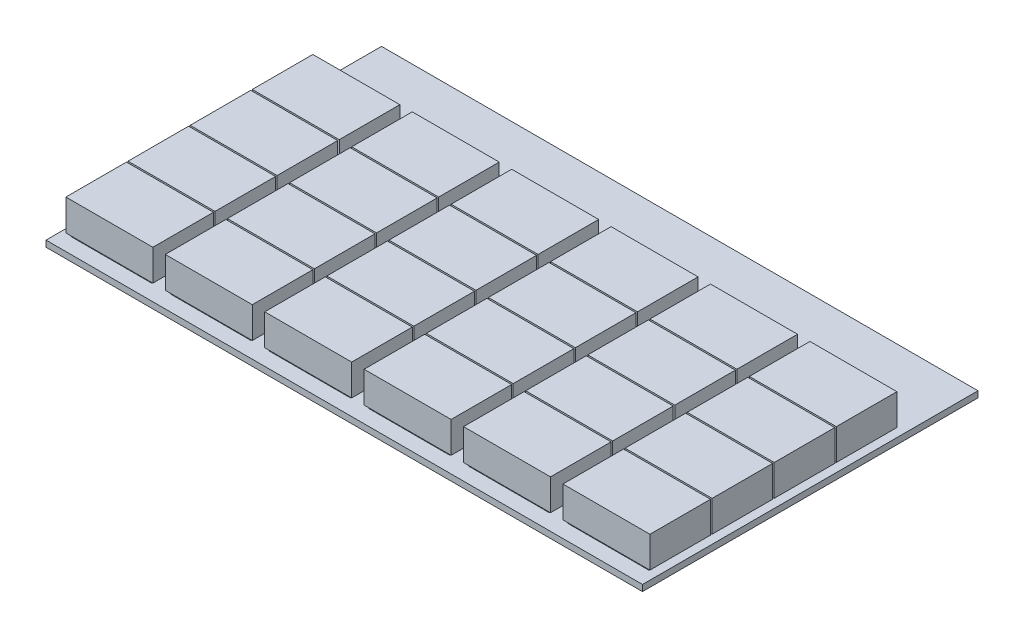
from build123d import *

# Parameters (mm, degrees)
SKETCH1_W                  = 80
SKETCH1_H                  = 270
BOSS_EXTRUDE1_DEPTH        = 5
SKETCH2_W                  = 65
SKETCH2_H                  = 45
BOSS_EXTRUDE3_DEPTH        = 2
LPATTERN1_COUNT            = 4
LPATTERN1_PITCH            = 50
SKETCH3_W                  = 70
SKETCH3_H                  = 48.748964222
BOSS_EXTRUDE8_DEPTH        = 25
LPATTERN5_COUNT            = 4
LPATTERN5_PITCH            = 50
LPATTERN6_COUNT            = 6
LPATTERN6_PITCH            = 80
LPATTERN6_COPY_1_SKETCH_W  = 65
LPATTERN6_COPY_1_SKETCH_H  = 45
LPATTERN6_COPY_1_DEPTH     = 2
LPATTERN6_COPY_2_SKETCH_W  = 65
LPATTERN6_COPY_2_SKETCH_H  = 45
LPATTERN6_COPY_2_DEPTH     = 2
LPATTERN6_COPY_3_SKETCH_W  = 65
LPATTERN6_COPY_3_SKETCH_H  = 45
LPATTERN6_COPY_3_DEPTH     = 2
LPATTERN6_COPY_4_SKETCH_W  = 65
LPATTERN6_COPY_4_SKETCH_H  = 45
LPATTERN6_COPY_4_DEPTH     = 2
LPATTERN6_COPY_5_SKETCH_W  = 65
LPATTERN6_COPY_5_SKETCH_H  = 45
LPATTERN6_COPY_5_DEPTH     = 2
LPATTERN6_COPY_6_SKETCH_W  = 65
LPATTERN6_COPY_6_SKETCH_H  = 45
LPATTERN6_COPY_6_DEPTH     = 2
LPATTERN6_COPY_7_SKETCH_W  = 65
LPATTERN6_COPY_7_SKETCH_H  = 45
LPATTERN6_COPY_7_DEPTH     = 2
LPATTERN6_COPY_8_SKETCH_W  = 65
LPATTERN6_COPY_8_SKETCH_H  = 45
LPATTERN6_COPY_8_DEPTH     = 2
LPATTERN6_COPY_9_SKETCH_W  = 65
LPATTERN6_COPY_9_SKETCH_H  = 45
LPATTERN6_COPY_9_DEPTH     = 2
LPATTERN6_COPY_10_SKETCH_W = 65
LPATTERN6_COPY_10_SKETCH_H = 45
LPATTERN6_COPY_10_DEPTH    = 2
LPATTERN6_COPY_11_SKETCH_W = 65
LPATTERN6_COPY_11_SKETCH_H = 45
LPATTERN6_COPY_11_DEPTH    = 2
LPATTERN6_COPY_12_SKETCH_W = 65
LPATTERN6_COPY_12_SKETCH_H = 45
LPATTERN6_COPY_12_DEPTH    = 2
LPATTERN6_COPY_13_SKETCH_W = 65
LPATTERN6_COPY_13_SKETCH_H = 45
LPATTERN6_COPY_13_DEPTH    = 2
LPATTERN6_COPY_14_SKETCH_W = 65
LPATTERN6_COPY_14_SKETCH_H = 45
LPATTERN6_COPY_14_DEPTH    = 2
LPATTERN6_COPY_15_SKETCH_W = 65
LPATTERN6_COPY_15_SKETCH_H = 45
LPATTERN6_COPY_15_DEPTH    = 2
LPATTERN6_COPY_16_SKETCH_W = 70
LPATTERN6_COPY_16_SKETCH_H = 48.748964222
LPATTERN6_COPY_16_DEPTH    = 25
LPATTERN6_COPY_17_SKETCH_W = 70
LPATTERN6_COPY_17_SKETCH_H = 48.748964222
LPATTERN6_COPY_17_DEPTH    = 25
LPATTERN6_COPY_18_SKETCH_W = 70
LPATTERN6_COPY_18_SKETCH_H = 48.748964222
LPATTERN6_COPY_18_DEPTH    = 25
LPATTERN6_COPY_19_SKETCH_W = 70
LPATTERN6_COPY_19_SKETCH_H = 48.748964222
LPATTERN6_COPY_19_DEPTH    = 25
LPATTERN6_COPY_20_SKETCH_W = 70
LPATTERN6_COPY_20_SKETCH_H = 48.748964222
LPATTERN6_COPY_20_DEPTH    = 25
LPATTERN6_COPY_21_SKETCH_W = 70
LPATTERN6_COPY_21_SKETCH_H = 48.748964222
LPATTERN6_COPY_21_DEPTH    = 25
LPATTERN6_COPY_22_SKETCH_W = 70
LPATTERN6_COPY_22_SKETCH_H = 48.748964222
LPATTERN6_COPY_22_DEPTH    = 25
LPATTERN6_COPY_23_SKETCH_W = 70
LPATTERN6_COPY_23_SKETCH_H = 48.748964222
LPATTERN6_COPY_23_DEPTH    = 25
LPATTERN6_COPY_24_SKETCH_W = 70
LPATTERN6_COPY_24_SKETCH_H = 48.748964222
LPATTERN6_COPY_24_DEPTH    = 25
LPATTERN6_COPY_25_SKETCH_W = 70
LPATTERN6_COPY_25_SKETCH_H = 48.748964222
LPATTERN6_COPY_25_DEPTH    = 25
LPATTERN6_COPY_26_SKETCH_W = 70
LPATTERN6_COPY_26_SKETCH_H = 48.748964222
LPATTERN6_COPY_26_DEPTH    = 25
LPATTERN6_COPY_27_SKETCH_W = 70
LPATTERN6_COPY_27_SKETCH_H = 48.748964222
LPATTERN6_COPY_27_DEPTH    = 25
LPATTERN6_COPY_28_SKETCH_W = 70
LPATTERN6_COPY_28_SKETCH_H = 48.748964222
LPATTERN6_COPY_28_DEPTH    = 25
LPATTERN6_COPY_29_SKETCH_W = 70
LPATTERN6_COPY_29_SKETCH_H = 48.748964222
LPATTERN6_COPY_29_DEPTH    = 25
LPATTERN6_COPY_30_SKETCH_W = 70
LPATTERN6_COPY_30_SKETCH_H = 48.748964222
LPATTERN6_COPY_30_DEPTH    = 25


with BuildPart() as part:
    # Sketch1 → Boss-Extrude1 (new body)
    with BuildSketch(Plane(origin=(0, 0, 0), x_dir=(1, 0, 0), z_dir=(0, 1, 0))):
        Rectangle(SKETCH1_W, SKETCH1_H)
    boss_extrude1 = extrude(amount=BOSS_EXTRUDE1_DEPTH)

    # Sketch2 → Boss-Extrude3 (add)
    with BuildSketch(Plane(origin=(0, 5, 0), x_dir=(1, 0, 0), z_dir=(0, 1, 0))):
        with Locations((0, -100)):
            Rectangle(SKETCH2_W, SKETCH2_H)
    boss_extrude3 = extrude(amount=BOSS_EXTRUDE3_DEPTH)

    # LPattern1: Boss-Extrude3 ×4
    with Locations(*[(0, 0, -i * LPATTERN1_PITCH) for i in range(1, LPATTERN1_COUNT)]):
        add(boss_extrude3)

    # Sketch3 → Boss-Extrude8 (add)
    with BuildSketch(Plane(origin=(0, 7, 0), x_dir=(1, 0, 0), z_dir=(0, 1, 0))):
        with Locations((0, -99.635002086)):
            Rectangle(SKETCH3_W, SKETCH3_H)
    boss_extrude8 = extrude(amount=BOSS_EXTRUDE8_DEPTH)

    # LPattern5: Boss-Extrude8 ×4
    with Locations(*[(0, 0, -i * LPATTERN5_PITCH) for i in range(1, LPATTERN5_COUNT)]):
        add(boss_extrude8)

    # LPattern6: Boss-Extrude1, Boss-Extrude3, Boss-Extrude8 ×6
    with Locations(*[(-i * LPATTERN6_PITCH, 0, 0) for i in range(1, LPATTERN6_COUNT)]):
        add(boss_extrude1)
        add(boss_extrude3)
        add(boss_extrude8)

    # LPattern6 copy 1 sketch → LPattern6 copy 1 (add)
    with BuildSketch(Plane(origin=(-80, 5, -50), x_dir=(1, 0, 0), z_dir=(0, 1, 0))):
        with Locations((0, -100)):
            Rectangle(LPATTERN6_COPY_1_SKETCH_W, LPATTERN6_COPY_1_SKETCH_H)
    extrude(amount=LPATTERN6_COPY_1_DEPTH)

    # LPattern6 copy 2 sketch → LPattern6 copy 2 (add)
    with BuildSketch(Plane(origin=(-160, 5, -50), x_dir=(1, 0, 0), z_dir=(0, 1, 0))):
        with Locations((0, -100)):
            Rectangle(LPATTERN6_COPY_2_SKETCH_W, LPATTERN6_COPY_2_SKETCH_H)
    extrude(amount=LPATTERN6_COPY_2_DEPTH)

    # LPattern6 copy 3 sketch → LPattern6 copy 3 (add)
    with BuildSketch(Plane(origin=(-240, 5, -50), x_dir=(1, 0, 0), z_dir=(0, 1, 0))):
        with Locations((0, -100)):
            Rectangle(LPATTERN6_COPY_3_SKETCH_W, LPATTERN6_COPY_3_SKETCH_H)
    extrude(amount=LPATTERN6_COPY_3_DEPTH)

    # LPattern6 copy 4 sketch → LPattern6 copy 4 (add)
    with BuildSketch(Plane(origin=(-320, 5, -50), x_dir=(1, 0, 0), z_dir=(0, 1, 0))):
        with Locations((0, -100)):
            Rectangle(LPATTERN6_COPY_4_SKETCH_W, LPATTERN6_COPY_4_SKETCH_H)
    extrude(amount=LPATTERN6_COPY_4_DEPTH)

    # LPattern6 copy 5 sketch → LPattern6 copy 5 (add)
    with BuildSketch(Plane(origin=(-400, 5, -50), x_dir=(1, 0, 0), z_dir=(0, 1, 0))):
        with Locations((0, -100)):
            Rectangle(LPATTERN6_COPY_5_SKETCH_W, LPATTERN6_COPY_5_SKETCH_H)
    extrude(amount=LPATTERN6_COPY_5_DEPTH)

    # LPattern6 copy 6 sketch → LPattern6 copy 6 (add)
    with BuildSketch(Plane(origin=(-80, 5, -100), x_dir=(1, 0, 0), z_dir=(0, 1, 0))):
        with Locations((0, -100)):
            Rectangle(LPATTERN6_COPY_6_SKETCH_W, LPATTERN6_COPY_6_SKETCH_H)
    extrude(amount=LPATTERN6_COPY_6_DEPTH)

    # LPattern6 copy 7 sketch → LPattern6 copy 7 (add)
    with BuildSketch(Plane(origin=(-160, 5, -100), x_dir=(1, 0, 0), z_dir=(0, 1, 0))):
        with Locations((0, -100)):
            Rectangle(LPATTERN6_COPY_7_SKETCH_W, LPATTERN6_COPY_7_SKETCH_H)
    extrude(amount=LPATTERN6_COPY_7_DEPTH)

    # LPattern6 copy 8 sketch → LPattern6 copy 8 (add)
    with BuildSketch(Plane(origin=(-240, 5, -100), x_dir=(1, 0, 0), z_dir=(0, 1, 0))):
        with Locations((0, -100)):
            Rectangle(LPATTERN6_COPY_8_SKETCH_W, LPATTERN6_COPY_8_SKETCH_H)
    extrude(amount=LPATTERN6_COPY_8_DEPTH)

    # LPattern6 copy 9 sketch → LPattern6 copy 9 (add)
    with BuildSketch(Plane(origin=(-320, 5, -100), x_dir=(1, 0, 0), z_dir=(0, 1, 0))):
        with Locations((0, -100)):
            Rectangle(LPATTERN6_COPY_9_SKETCH_W, LPATTERN6_COPY_9_SKETCH_H)
    extrude(amount=LPATTERN6_COPY_9_DEPTH)

    # LPattern6 copy 10 sketch → LPattern6 copy 10 (add)
    with BuildSketch(Plane(origin=(-400, 5, -100), x_dir=(1, 0, 0), z_dir=(0, 1, 0))):
        with Locations((0, -100)):
            Rectangle(LPATTERN6_COPY_10_SKETCH_W, LPATTERN6_COPY_10_SKETCH_H)
    extrude(amount=LPATTERN6_COPY_10_DEPTH)

    # LPattern6 copy 11 sketch → LPattern6 copy 11 (add)
    with BuildSketch(Plane(origin=(-80, 5, -150), x_dir=(1, 0, 0), z_dir=(0, 1, 0))):
        with Locations((0, -100)):
            Rectangle(LPATTERN6_COPY_11_SKETCH_W, LPATTERN6_COPY_11_SKETCH_H)
    extrude(amount=LPATTERN6_COPY_11_DEPTH)

    # LPattern6 copy 12 sketch → LPattern6 copy 12 (add)
    with BuildSketch(Plane(origin=(-160, 5, -150), x_dir=(1, 0, 0), z_dir=(0, 1, 0))):
        with Locations((0, -100)):
            Rectangle(LPATTERN6_COPY_12_SKETCH_W, LPATTERN6_COPY_12_SKETCH_H)
    extrude(amount=LPATTERN6_COPY_12_DEPTH)

    # LPattern6 copy 13 sketch → LPattern6 copy 13 (add)
    with BuildSketch(Plane(origin=(-240, 5, -150), x_dir=(1, 0, 0), z_dir=(0, 1, 0))):
        with Locations((0, -100)):
            Rectangle(LPATTERN6_COPY_13_SKETCH_W, LPATTERN6_COPY_13_SKETCH_H)
    extrude(amount=LPATTERN6_COPY_13_DEPTH)

    # LPattern6 copy 14 sketch → LPattern6 copy 14 (add)
    with BuildSketch(Plane(origin=(-320, 5, -150), x_dir=(1, 0, 0), z_dir=(0, 1, 0))):
        with Locations((0, -100)):
            Rectangle(LPATTERN6_COPY_14_SKETCH_W, LPATTERN6_COPY_14_SKETCH_H)
    extrude(amount=LPATTERN6_COPY_14_DEPTH)

    # LPattern6 copy 15 sketch → LPattern6 copy 15 (add)
    with BuildSketch(Plane(origin=(-400, 5, -150), x_dir=(1, 0, 0), z_dir=(0, 1, 0))):
        with Locations((0, -100)):
            Rectangle(LPATTERN6_COPY_15_SKETCH_W, LPATTERN6_COPY_15_SKETCH_H)
    extrude(amount=LPATTERN6_COPY_15_DEPTH)

    # LPattern6 copy 16 sketch → LPattern6 copy 16 (add)
    with BuildSketch(Plane(origin=(-80, 7, -50), x_dir=(1, 0, 0), z_dir=(0, 1, 0))):
        with Locations((0, -99.635002086)):
            Rectangle(LPATTERN6_COPY_16_SKETCH_W, LPATTERN6_COPY_16_SKETCH_H)
    extrude(amount=LPATTERN6_COPY_16_DEPTH)

    # LPattern6 copy 17 sketch → LPattern6 copy 17 (add)
    with BuildSketch(Plane(origin=(-160, 7, -50), x_dir=(1, 0, 0), z_dir=(0, 1, 0))):
        with Locations((0, -99.635002086)):
            Rectangle(LPATTERN6_COPY_17_SKETCH_W, LPATTERN6_COPY_17_SKETCH_H)
    extrude(amount=LPATTERN6_COPY_17_DEPTH)

    # LPattern6 copy 18 sketch → LPattern6 copy 18 (add)
    with BuildSketch(Plane(origin=(-240, 7, -50), x_dir=(1, 0, 0), z_dir=(0, 1, 0))):
        with Locations((0, -99.635002086)):
            Rectangle(LPATTERN6_COPY_18_SKETCH_W, LPATTERN6_COPY_18_SKETCH_H)
    extrude(amount=LPATTERN6_COPY_18_DEPTH)

    # LPattern6 copy 19 sketch → LPattern6 copy 19 (add)
    with BuildSketch(Plane(origin=(-320, 7, -50), x_dir=(1, 0, 0), z_dir=(0, 1, 0))):
        with Locations((0, -99.635002086)):
            Rectangle(LPATTERN6_COPY_19_SKETCH_W, LPATTERN6_COPY_19_SKETCH_H)
    extrude(amount=LPATTERN6_COPY_19_DEPTH)

    # LPattern6 copy 20 sketch → LPattern6 copy 20 (add)
    with BuildSketch(Plane(origin=(-400, 7, -50), x_dir=(1, 0, 0), z_dir=(0, 1, 0))):
        with Locations((0, -99.635002086)):
            Rectangle(LPATTERN6_COPY_20_SKETCH_W, LPATTERN6_COPY_20_SKETCH_H)
    extrude(amount=LPATTERN6_COPY_20_DEPTH)

    # LPattern6 copy 21 sketch → LPattern6 copy 21 (add)
    with BuildSketch(Plane(origin=(-80, 7, -100), x_dir=(1, 0, 0), z_dir=(0, 1, 0))):
        with Locations((0, -99.635002086)):
            Rectangle(LPATTERN6_COPY_21_SKETCH_W, LPATTERN6_COPY_21_SKETCH_H)
    extrude(amount=LPATTERN6_COPY_21_DEPTH)

    # LPattern6 copy 22 sketch → LPattern6 copy 22 (add)
    with BuildSketch(Plane(origin=(-160, 7, -100), x_dir=(1, 0, 0), z_dir=(0, 1, 0))):
        with Locations((0, -99.635002086)):
            Rectangle(LPATTERN6_COPY_22_SKETCH_W, LPATTERN6_COPY_22_SKETCH_H)
    extrude(amount=LPATTERN6_COPY_22_DEPTH)

    # LPattern6 copy 23 sketch → LPattern6 copy 23 (add)
    with BuildSketch(Plane(origin=(-240, 7, -100), x_dir=(1, 0, 0), z_dir=(0, 1, 0))):
        with Locations((0, -99.635002086)):
            Rectangle(LPATTERN6_COPY_23_SKETCH_W, LPATTERN6_COPY_23_SKETCH_H)
    extrude(amount=LPATTERN6_COPY_23_DEPTH)

    # LPattern6 copy 24 sketch → LPattern6 copy 24 (add)
    with BuildSketch(Plane(origin=(-320, 7, -100), x_dir=(1, 0, 0), z_dir=(0, 1, 0))):
        with Locations((0, -99.635002086)):
            Rectangle(LPATTERN6_COPY_24_SKETCH_W, LPATTERN6_COPY_24_SKETCH_H)
    extrude(amount=LPATTERN6_COPY_24_DEPTH)

    # LPattern6 copy 25 sketch → LPattern6 copy 25 (add)
    with BuildSketch(Plane(origin=(-400, 7, -100), x_dir=(1, 0, 0), z_dir=(0, 1, 0))):
        with Locations((0, -99.635002086)):
            Rectangle(LPATTERN6_COPY_25_SKETCH_W, LPATTERN6_COPY_25_SKETCH_H)
    extrude(amount=LPATTERN6_COPY_25_DEPTH)

    # LPattern6 copy 26 sketch → LPattern6 copy 26 (add)
    with BuildSketch(Plane(origin=(-80, 7, -150), x_dir=(1, 0, 0), z_dir=(0, 1, 0))):
        with Locations((0, -99.635002086)):
            Rectangle(LPATTERN6_COPY_26_SKETCH_W, LPATTERN6_COPY_26_SKETCH_H)
    extrude(amount=LPATTERN6_COPY_26_DEPTH)

    # LPattern6 copy 27 sketch → LPattern6 copy 27 (add)
    with BuildSketch(Plane(origin=(-160, 7, -150), x_dir=(1, 0, 0), z_dir=(0, 1, 0))):
        with Locations((0, -99.635002086)):
            Rectangle(LPATTERN6_COPY_27_SKETCH_W, LPATTERN6_COPY_27_SKETCH_H)
    extrude(amount=LPATTERN6_COPY_27_DEPTH)

    # LPattern6 copy 28 sketch → LPattern6 copy 28 (add)
    with BuildSketch(Plane(origin=(-240, 7, -150), x_dir=(1, 0, 0), z_dir=(0, 1, 0))):
        with Locations((0, -99.635002086)):
            Rectangle(LPATTERN6_COPY_28_SKETCH_W, LPATTERN6_COPY_28_SKETCH_H)
    extrude(amount=LPATTERN6_COPY_28_DEPTH)

    # LPattern6 copy 29 sketch → LPattern6 copy 29 (add)
    with BuildSketch(Plane(origin=(-320, 7, -150), x_dir=(1, 0, 0), z_dir=(0, 1, 0))):
        with Locations((0, -99.635002086)):
            Rectangle(LPATTERN6_COPY_29_SKETCH_W, LPATTERN6_COPY_29_SKETCH_H)
    extrude(amount=LPATTERN6_COPY_29_DEPTH)

    # LPattern6 copy 30 sketch → LPattern6 copy 30 (add)
    with BuildSketch(Plane(origin=(-400, 7, -150), x_dir=(1, 0, 0), z_dir=(0, 1, 0))):
        with Locations((0, -99.635002086)):
            Rectangle(LPATTERN6_COPY_30_SKETCH_W, LPATTERN6_COPY_30_SKETCH_H)
    extrude(amount=LPATTERN6_COPY_30_DEPTH)


solid = part.part
